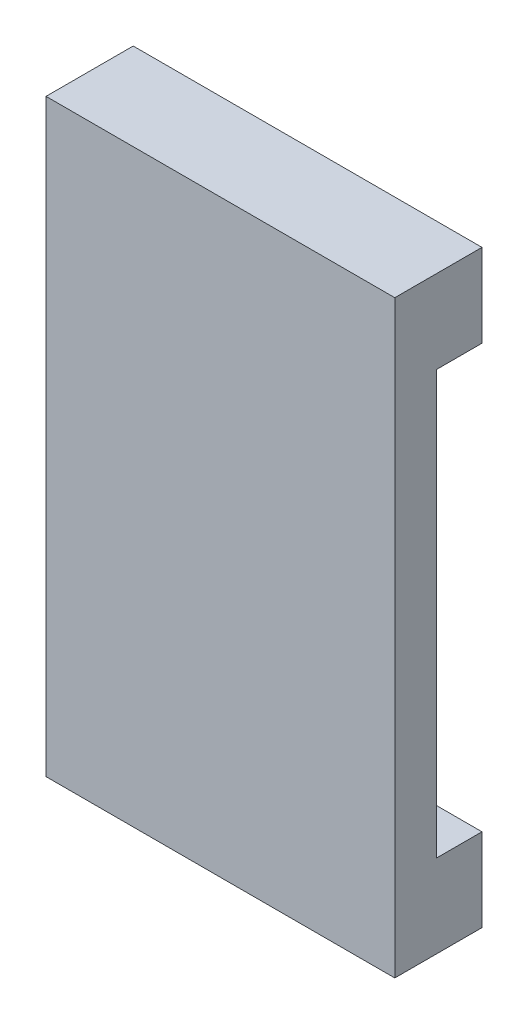
from build123d import *

# Parameters (mm, degrees)
SALIENTE_EXTRUIR1_DEPTH = 5.5
CROQUIS2_W              = 42
CROQUIS2_H              = 70.95
SALIENTE_EXTRUIR2_DEPTH = 5


with BuildPart() as part:
    # Croquis1 → Saliente-Extruir1 (new body)
    with BuildSketch(Plane.XY):
        Polygon((-16, -25.435), (-16, 25.515), (16, 25.515), (16, 35.515), (-26, 35.515), (-26, -35.435), (16, -35.435), (16, -25.435), align=None)
    extrude(amount=SALIENTE_EXTRUIR1_DEPTH)

    # Croquis2 → Saliente-Extruir2 (add)
    with BuildSketch(Plane.XY.offset(5.5)):
        with Locations((-5, 0.04)):
            Rectangle(CROQUIS2_W, CROQUIS2_H)
    extrude(amount=SALIENTE_EXTRUIR2_DEPTH)


solid = part.part
